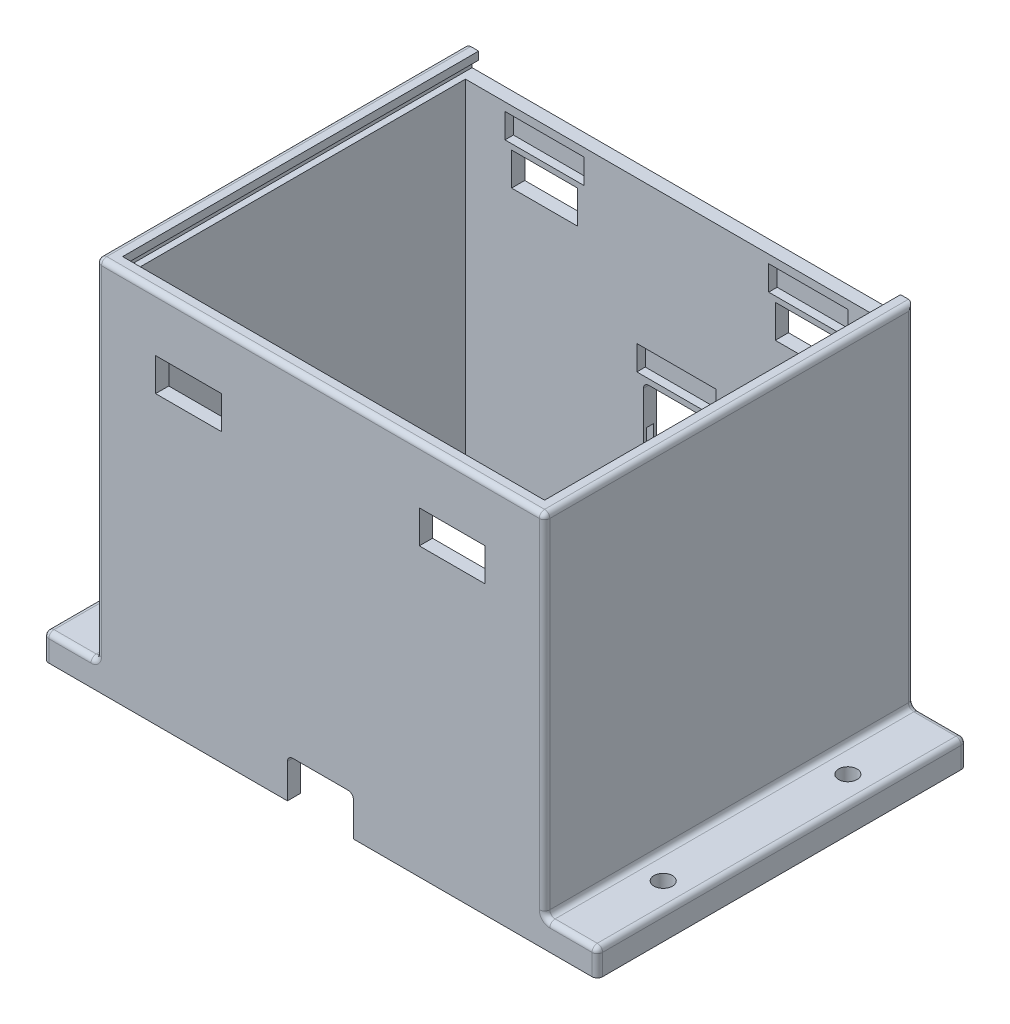
from build123d import *

# Parameters (mm, degrees)
BOSS_EXTRUDE1_DEPTH      = 170
SKETCH7_W                = 5
SKETCH7_H                = 142.5
BOSS_EXTRUDE2_DEPTH      = 130
SKETCH9_W                = 160
SKETCH9_H                = 130
CUT_EXTRUDE2_DEPTH       = 60
SKETCH10_W               = 165
SKETCH10_H               = 3.7
CUT_EXTRUDE3_DEPTH       = 137.5
SKETCH13_W               = 160
SKETCH13_H               = 6
CUT_EXTRUDE4_DEPTH       = 5
SKETCH15_W               = 20
SKETCH15_H               = 10
BOSS_EXTRUDE3_DEPTH      = 70
SKETCH16_W               = 25
SKETCH16_H               = 12.5
CUT_EXTRUDE5_DEPTH       = 5
M6_CLEARANCE_HOLE1_D     = 7
M6_CLEARANCE_HOLE1_DEPTH = 10
SKETCH26_W               = 30
SKETCH26_H               = 9.35
CUT_EXTRUDE6_DEPTH       = 68.2
SKETCH27_W               = 30
SKETCH27_H               = 9.35
CUT_EXTRUDE8_DEPTH       = 68.2
CUT_EXTRUDE10_DEPTH      = 5
CUT_EXTRUDE11_DEPTH      = 5
SKETCH30_W               = 30
SKETCH30_H               = 9.35
CUT_EXTRUDE12_DEPTH      = 68.2
CUT_EXTRUDE14_DEPTH      = 54.5
FILLET1_R                = 2


with BuildPart() as part:
    # Sketch1 → Boss-Extrude1 (new body)
    with BuildSketch(Plane(origin=(0, 0, 0), x_dir=(0, 0, -1), z_dir=(1, 0, 0))):
        Polygon((90, 142.5), (90, 0), (85, 0), (85, 137.5), (-45, 137.5), (-45, 0), (-50, 0), (-50, 142.5), align=None)
    extrude(amount=BOSS_EXTRUDE1_DEPTH)

    # Sketch7 → Boss-Extrude2 (add)
    with BuildSketch(Plane(origin=(0, 0, 45), x_dir=(-1, 0, 0), z_dir=(0, 0, -1))):
        with Locations((-167.5, 71.25)):
            Rectangle(SKETCH7_W, SKETCH7_H)
        with Locations((-2.5, 71.25)):
            Rectangle(SKETCH7_W, SKETCH7_H)
    extrude(amount=BOSS_EXTRUDE2_DEPTH)

    # Sketch9 → Cut-Extrude2 (cut)
    with BuildSketch(Plane(origin=(0, 142.5, 0), x_dir=(1, 0, 0), z_dir=(0, 1, 0))):
        with Locations((85, 20)):
            Rectangle(SKETCH9_W, SKETCH9_H)
    extrude(amount=-CUT_EXTRUDE2_DEPTH, mode=Mode.SUBTRACT)

    # Sketch10 → Cut-Extrude3 (cut)
    with BuildSketch(Plane(origin=(80, 0, -90), x_dir=(1, 0, 0), z_dir=(0, 0, 1))):
        with Locations((5, 137.65)):
            Rectangle(SKETCH10_W, SKETCH10_H)
    extrude(amount=CUT_EXTRUDE3_DEPTH, mode=Mode.SUBTRACT)

    # Sketch13 → Cut-Extrude4 (cut)
    with BuildSketch(Plane(origin=(80, 0, -90), x_dir=(1, 0, 0), z_dir=(0, 0, 1))):
        with Locations((5, 139.5)):
            Rectangle(SKETCH13_W, SKETCH13_H)
    extrude(amount=CUT_EXTRUDE4_DEPTH, mode=Mode.SUBTRACT)

    # Sketch15 → Boss-Extrude3 (add, symmetric)
    with BuildSketch(Plane.XY.offset(-20)):
        with Locations((-10, 5)):
            Rectangle(SKETCH15_W, SKETCH15_H)
        with Locations((180, 5)):
            Rectangle(SKETCH15_W, SKETCH15_H)
    extrude(amount=BOSS_EXTRUDE3_DEPTH, both=True)

    # Sketch16 → Cut-Extrude5 (cut)
    with BuildSketch(Plane.XY.offset(50)):
        with Locations((35, 115)):
            Rectangle(SKETCH16_W, SKETCH16_H)
        with Locations((135, 115)):
            Rectangle(SKETCH16_W, SKETCH16_H)
    cut_extrude5 = extrude(amount=-CUT_EXTRUDE5_DEPTH, mode=Mode.SUBTRACT)

    # M6 Clearance Hole1
    with Locations(Plane(origin=(0, 10, 0), x_dir=(1, 0, 0), z_dir=(0, 1, 0))):
        with Locations((-10, -15), (-10, 55), (180, 55), (180, -15)):
            Hole(M6_CLEARANCE_HOLE1_D / 2, depth=M6_CLEARANCE_HOLE1_DEPTH)

    # Mirror2: Cut-Extrude5 across plane
    add(cut_extrude5.mirror(Plane.XY.offset(-20)), mode=Mode.SUBTRACT)

    # Sketch26 → Cut-Extrude6 (cut, symmetric)
    with BuildSketch(Plane.XY.offset(-20)):
        with Locations((135, 128)):
            Rectangle(SKETCH26_W, SKETCH26_H)
        with Locations((35, 128)):
            Rectangle(SKETCH26_W, SKETCH26_H)
    extrude(amount=CUT_EXTRUDE6_DEPTH, both=True, mode=Mode.SUBTRACT)

    # Sketch27 → Cut-Extrude8 (cut)
    with BuildSketch(Plane.XY.offset(-20)):
        with Locations((85, 21.8)):
            Rectangle(SKETCH27_W, SKETCH27_H)
    extrude(amount=CUT_EXTRUDE8_DEPTH, mode=Mode.SUBTRACT)

    # Sketch28 → Cut-Extrude10 (cut)
    with BuildSketch(Plane(origin=(0, 0, 50), x_dir=(-1, 0, 0), z_dir=(0, 0, -1))):
        with BuildLine():
            Line((-72.5, 0), (-72.5, 13))
            ThreePointArc((-72.5, 13), (-73.085786438, 14.414213562), (-74.5, 15))
            Line((-74.5, 15), (-95.5, 15))
            ThreePointArc((-95.5, 15), (-96.914213562, 14.414213562), (-97.5, 13))
            Line((-97.5, 13), (-97.5, 0))
            Line((-97.5, 0), (-72.5, 0))
        make_face()
    extrude(amount=CUT_EXTRUDE10_DEPTH, mode=Mode.SUBTRACT)

    # Sketch29 → Cut-Extrude11 (cut)
    with BuildSketch(Plane.XY.offset(-90)):
        with BuildLine():
            Line((95.5, 52.5), (74.5, 52.5))
            ThreePointArc((74.5, 52.5), (73.085786438, 53.085786438), (72.5, 54.5))
            Line((72.5, 54.5), (72.5, 68))
            ThreePointArc((72.5, 68), (73.085786438, 69.414213562), (74.5, 70))
            Line((74.5, 70), (95.5, 70))
            ThreePointArc((95.5, 70), (96.914213562, 69.414213562), (97.5, 68))
            Line((97.5, 68), (97.5, 54.5))
            ThreePointArc((97.5, 54.5), (96.914213562, 53.085786438), (95.5, 52.5))
        make_face()
    extrude(amount=CUT_EXTRUDE11_DEPTH, mode=Mode.SUBTRACT)

    # Sketch30 → Cut-Extrude12 (cut)
    with BuildSketch(Plane.XY.offset(-20)):
        with Locations((85, 76.8)):
            Rectangle(SKETCH30_W, SKETCH30_H)
    extrude(amount=-CUT_EXTRUDE12_DEPTH, mode=Mode.SUBTRACT)

    # Sketch31 → Cut-Extrude14 (cut)
    with BuildSketch(Plane(origin=(0, 0, 0), x_dir=(1, 0, 0), z_dir=(0, 1, 0))):
        Polygon((97.5, 86.25), (100.5, 86.25), (100.5, 88.75), (97.5, 88.75), (97.5, 90), (72.5, 90), (72.5, 88.75), (69.5, 88.75), (69.5, 86.25), (72.5, 86.25), (72.5, 85), (97.5, 85), align=None)
    extrude(amount=CUT_EXTRUDE14_DEPTH, mode=Mode.SUBTRACT)

    # Fillet1
    fillet1_edges = [part.edges().sort_by_distance(p)[0] for p in [
        (0, 76.25, 50),
        (0, 142.5, -20),
        (0, 76.25, -90),
        (-10, 10, -90),
        (0, 10, -20),
        (-20, 5, -90),
        (-20, 10, -20),
        (-10, 10, 50),
        (-20, 5, 50),
        (190, 5, -90),
        (180, 10, -90),
        (190, 10, -20),
        (170, 10, -20),
        (190, 5, 50),
        (180, 10, 50),
        (85, 142.5, 50),
        (170, 76.25, -90),
        (170, 142.5, -20),
        (170, 76.25, 50),
    ]]
    fillet(fillet1_edges, radius=FILLET1_R)


solid = part.part
